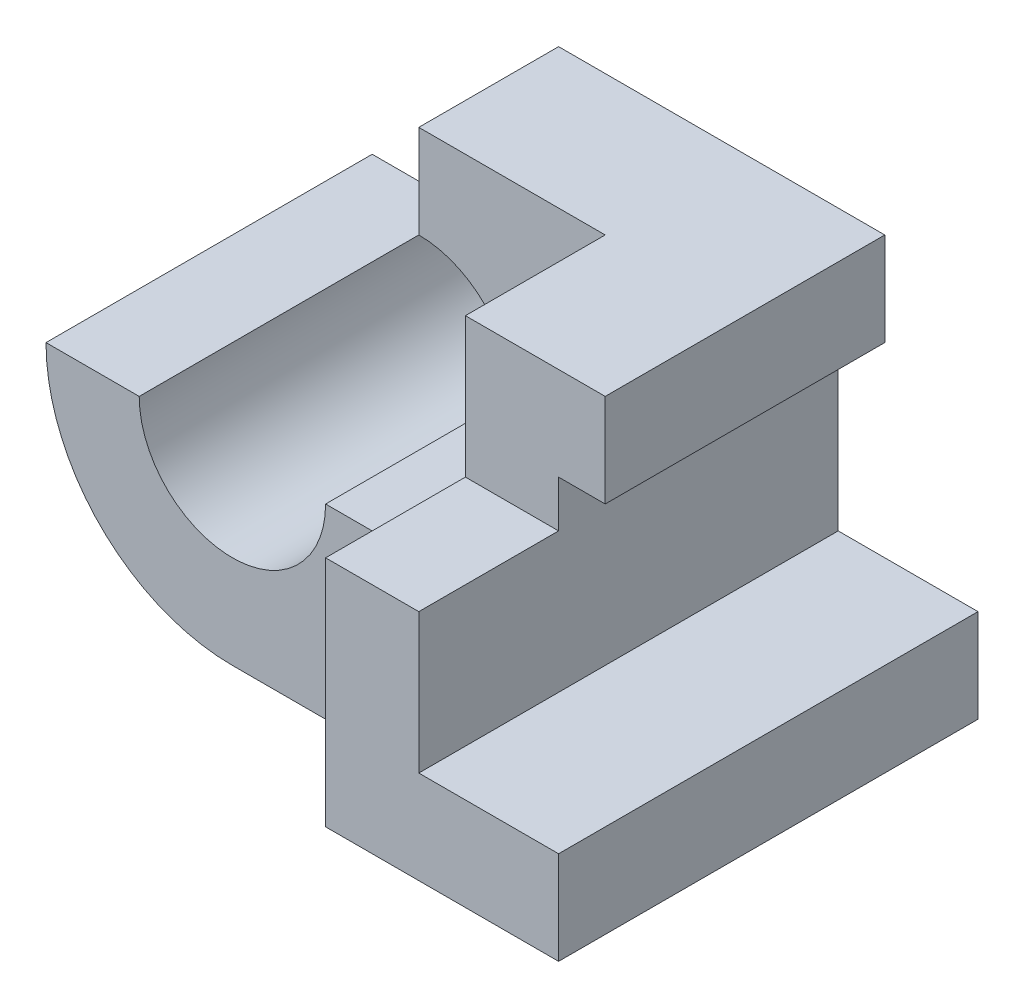
from build123d import *

# Parameters (mm, degrees)
BOSS_EXTRUDE1_DEPTH  = 90
SKETCH2_W            = 30
SKETCH2_H            = 40
CUT_EXTRUDE1_DEPTH   = 90
SKETCH3_W            = 20
SKETCH3_H            = 20
CUT_EXTRUDE2_DEPTH   = 90
SKETCH4_W            = 80
SKETCH4_H            = 20
CUT_EXTRUDE3_DEPTH   = 90
SKETCH5_W            = 30
SKETCH5_H            = 30
CUT_EXTRUDE4_DEPTH   = 90
CUT_EXTRUDE6_DEPTH   = 40
BOSS_EXTRUDE6_DEPTH  = 30
CUT_EXTRUDE7_DEPTH   = 20
SKETCH12_W           = 10
SKETCH12_H           = 30
CUT_EXTRUDE8_DEPTH   = 20
SKETCH13_W           = 20
SKETCH13_H           = 30
CUT_EXTRUDE9_DEPTH   = 20
SKETCH14_W           = 21.421822341
SKETCH14_H           = 40
BOSS_EXTRUDE7_DEPTH  = 10
SKETCH16_W           = 20
SKETCH16_H           = 60
BOSS_EXTRUDE8_DEPTH  = 30
SKETCH17_W           = 30
SKETCH17_H           = 30
CUT_EXTRUDE10_DEPTH  = 20
SKETCH18_W           = 90
SKETCH18_H           = 30
BOSS_EXTRUDE9_DEPTH  = 10
SKETCH19_W           = 90
SKETCH19_H           = 20
BOSS_EXTRUDE10_DEPTH = 20
SKETCH21_W           = 10.0001
SKETCH21_H           = 30
BOSS_EXTRUDE13_DEPTH = 30
SKETCH22_W           = 10
SKETCH22_H           = 30
CUT_EXTRUDE13_DEPTH  = 29.999
SKETCH23_W           = 30
SKETCH23_H           = 29.999
CUT_EXTRUDE14_DEPTH  = 1
SKETCH24_W           = 10.0001
SKETCH24_H           = 30
CUT_EXTRUDE15_DEPTH  = 1
SKETCH25_W           = 10
SKETCH25_H           = 30
CUT_EXTRUDE16_DEPTH  = 10
SKETCH27_W           = 10
SKETCH27_H           = 10
CUT_EXTRUDE18_DEPTH  = 30
SKETCH30_W           = 20
SKETCH30_H           = 20
BOSS_EXTRUDE16_DEPTH = 30
SKETCH31_W           = 30
SKETCH31_H           = 20
BOSS_EXTRUDE17_DEPTH = 10


with BuildPart() as part:
    # Sketch1 → Boss-Extrude1 (new body)
    with BuildSketch(Plane.XY):
        with BuildLine():
            ThreePointArc((0, -40), (40, 0), (0, 40))
            Line((0, 40), (0, 20))
            ThreePointArc((0, 20), (14.142135624, 14.142135624), (20, 0))
            ThreePointArc((20, 0), (0, -20), (-20, 0))
            Line((-20, 0), (-40, 0))
            ThreePointArc((-40, 0), (-28.284271247, -28.284271247), (0, -40))
        make_face()
        with BuildLine():
            Line((70, 40), (0, 40))
            ThreePointArc((0, 40), (40, 0), (0, -40))
            Line((0, -40), (70, -40))
            Line((70, -40), (70, 40))
        make_face()
    extrude(amount=BOSS_EXTRUDE1_DEPTH)

    # Sketch2 → Cut-Extrude1 (cut)
    with BuildSketch(Plane.XY.offset(90)):
        with Locations((55, 0)):
            Rectangle(SKETCH2_W, SKETCH2_H)
    extrude(amount=-CUT_EXTRUDE1_DEPTH, mode=Mode.SUBTRACT)

    # Sketch3 → Cut-Extrude2 (cut)
    with BuildSketch(Plane.XY.offset(90)):
        with Locations((60, 30)):
            Rectangle(SKETCH3_W, SKETCH3_H)
    extrude(amount=-CUT_EXTRUDE2_DEPTH, mode=Mode.SUBTRACT)

    # Sketch4 → Cut-Extrude3 (cut)
    with BuildSketch(Plane(origin=(0, -40, 0), x_dir=(1, 0, 0), z_dir=(0, 1, 0))):
        with Locations((0, -80)):
            Rectangle(SKETCH4_W, SKETCH4_H)
    extrude(amount=CUT_EXTRUDE3_DEPTH, mode=Mode.SUBTRACT)

    # Sketch5 → Cut-Extrude4 (cut)
    with BuildSketch(Plane(origin=(0, 0, 0), x_dir=(0, 0, -1), z_dir=(1, 0, 0))):
        with Locations((-85, 25)):
            Rectangle(SKETCH5_W, SKETCH5_H)
    extrude(amount=CUT_EXTRUDE4_DEPTH, mode=Mode.SUBTRACT)

    # Sketch7 → Cut-Extrude6 (cut)
    with BuildSketch(Plane.XY.offset(70)):
        with BuildLine():
            Line((20, 0), (40, 0))
            Line((40, 0), (40, 40))
            Line((40, 40), (0, 40))
            Line((0, 40), (0, 20))
            ThreePointArc((0, 20), (14.142135624, 14.142135624), (20, 0))
        make_face()
    extrude(amount=-CUT_EXTRUDE6_DEPTH, mode=Mode.SUBTRACT)

    # Sketch10 → Boss-Extrude6 (add)
    with BuildSketch(Plane(origin=(70, 0, 0), x_dir=(0, 0, -1), z_dir=(1, 0, 0))):
        Polygon((-70, 20), (-70, 10), (-90, 10), (-90, -20), (-37.089362558, -20), (-21.421822341, -20), (-21.421822341, 20), align=None)
    extrude(amount=-BOSS_EXTRUDE6_DEPTH)

    # Sketch11 → Cut-Extrude7 (cut)
    with BuildSketch(Plane(origin=(70, 0, 0), x_dir=(0, 0, -1), z_dir=(1, 0, 0))):
        Polygon((-21.421822341, -20), (-70, -20), (-70, 10), (-70, 20), (-21.421822341, 20), align=None)
    extrude(amount=-CUT_EXTRUDE7_DEPTH, mode=Mode.SUBTRACT)

    # Sketch12 → Cut-Extrude8 (cut)
    with BuildSketch(Plane(origin=(50, 0, 0), x_dir=(0, 0, -1), z_dir=(1, 0, 0))):
        with Locations((-65, 25)):
            Rectangle(SKETCH12_W, SKETCH12_H)
    extrude(amount=-CUT_EXTRUDE8_DEPTH, mode=Mode.SUBTRACT)

    # Sketch13 → Cut-Extrude9 (cut)
    with BuildSketch(Plane(origin=(0, 0, 70), x_dir=(-1, 0, 0), z_dir=(0, 0, -1))):
        with Locations((-60, -5)):
            Rectangle(SKETCH13_W, SKETCH13_H)
    extrude(amount=-CUT_EXTRUDE9_DEPTH, mode=Mode.SUBTRACT)

    # Sketch14 → Boss-Extrude7 (add)
    with BuildSketch(Plane(origin=(40, 0, 0), x_dir=(0, 0, -1), z_dir=(1, 0, 0))):
        with Locations((-10.710911171, 0)):
            Rectangle(SKETCH14_W, SKETCH14_H)
    extrude(amount=BOSS_EXTRUDE7_DEPTH)

    # Sketch16 → Boss-Extrude8 (add)
    with BuildSketch(Plane(origin=(0, 40, 0), x_dir=(1, 0, 0), z_dir=(0, 1, 0))):
        with Locations((60, -30)):
            Rectangle(SKETCH16_W, SKETCH16_H)
    extrude(amount=-BOSS_EXTRUDE8_DEPTH)

    # Sketch17 → Cut-Extrude10 (cut)
    with BuildSketch(Plane(origin=(70, 0, 0), x_dir=(0, 0, -1), z_dir=(1, 0, 0))):
        with Locations((-15, 25)):
            Rectangle(SKETCH17_W, SKETCH17_H)
    extrude(amount=-CUT_EXTRUDE10_DEPTH, mode=Mode.SUBTRACT)

    # Sketch18 → Boss-Extrude9 (add)
    with BuildSketch(Plane(origin=(50, 0, 0), x_dir=(0, 0, -1), z_dir=(1, 0, 0))):
        with Locations((-45, -5)):
            Rectangle(SKETCH18_W, SKETCH18_H)
    extrude(amount=BOSS_EXTRUDE9_DEPTH)

    # Sketch19 → Boss-Extrude10 (add)
    with BuildSketch(Plane(origin=(70, 0, 0), x_dir=(0, 0, -1), z_dir=(1, 0, 0))):
        with Locations((-45, -30)):
            Rectangle(SKETCH19_W, SKETCH19_H)
    extrude(amount=BOSS_EXTRUDE10_DEPTH)

    # Sketch21 → Boss-Extrude13 (add)
    with BuildSketch(Plane(origin=(0, 0, 30), x_dir=(-1, 0, 0), z_dir=(0, 0, -1))):
        with Locations((-64.99995, 25)):
            Rectangle(SKETCH21_W, SKETCH21_H)
    extrude(amount=BOSS_EXTRUDE13_DEPTH)

    # Sketch22 → Cut-Extrude13 (cut)
    with BuildSketch(Plane.XZ.offset(-10)):
        with Locations((65, 15)):
            Rectangle(SKETCH22_W, SKETCH22_H)
    extrude(amount=-CUT_EXTRUDE13_DEPTH, mode=Mode.SUBTRACT)

    # Sketch23 → Cut-Extrude14 (cut)
    with BuildSketch(Plane(origin=(60, 0, 0), x_dir=(0, 0, -1), z_dir=(1, 0, 0))):
        with Locations((-15, 24.9995)):
            Rectangle(SKETCH23_W, SKETCH23_H)
    extrude(amount=-CUT_EXTRUDE14_DEPTH, mode=Mode.SUBTRACT)

    # Sketch24 → Cut-Extrude15 (cut)
    with BuildSketch(Plane.XZ.offset(-39.999)):
        with Locations((64.99995, 15)):
            Rectangle(SKETCH24_W, SKETCH24_H)
    extrude(amount=-CUT_EXTRUDE15_DEPTH, mode=Mode.SUBTRACT)

    # Sketch25 → Cut-Extrude16 (cut)
    with BuildSketch(Plane(origin=(0, 10, 0), x_dir=(1, 0, 0), z_dir=(0, 1, 0))):
        with Locations((55, -15)):
            Rectangle(SKETCH25_W, SKETCH25_H)
    extrude(amount=-CUT_EXTRUDE16_DEPTH, mode=Mode.SUBTRACT)

    # Sketch27 → Cut-Extrude18 (cut)
    with BuildSketch(Plane.XY.offset(60)):
        with Locations((65, 15)):
            Rectangle(SKETCH27_W, SKETCH27_H)
    extrude(amount=-CUT_EXTRUDE18_DEPTH, mode=Mode.SUBTRACT)

    # Sketch30 → Boss-Extrude16 (add)
    with BuildSketch(Plane(origin=(0, 0, 30), x_dir=(-1, 0, 0), z_dir=(0, 0, -1))):
        with Locations((-60, 30)):
            Rectangle(SKETCH30_W, SKETCH30_H)
    extrude(amount=BOSS_EXTRUDE16_DEPTH)

    # Sketch31 → Boss-Extrude17 (add)
    with BuildSketch(Plane(origin=(50, 0, 0), x_dir=(0, 0, -1), z_dir=(1, 0, 0))):
        with Locations((-15, 10)):
            Rectangle(SKETCH31_W, SKETCH31_H)
    extrude(amount=BOSS_EXTRUDE17_DEPTH)


solid = part.part
